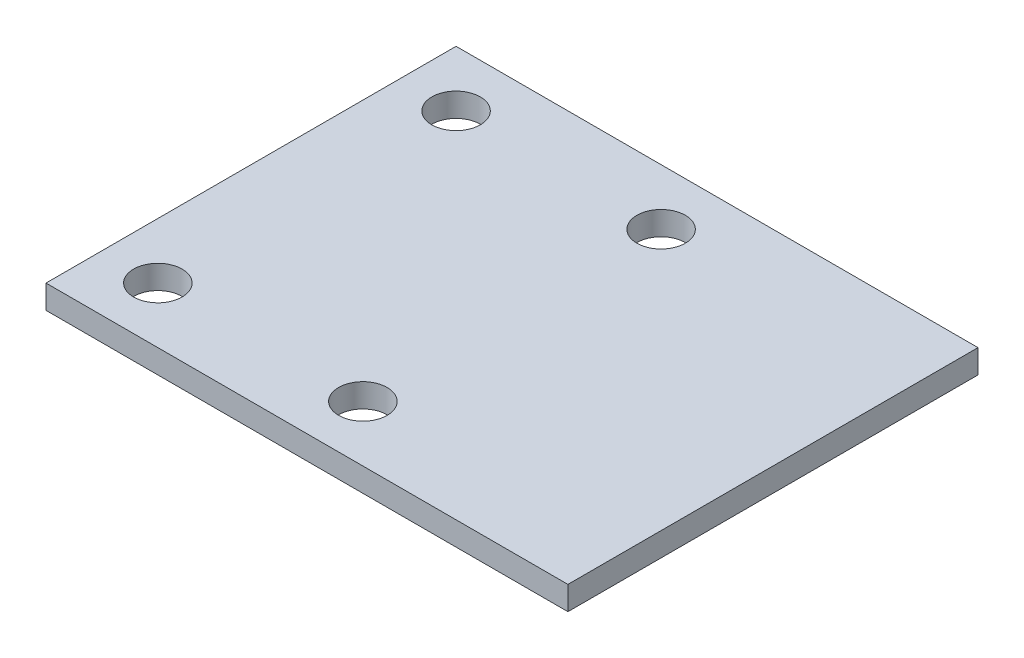
from build123d import *

# Parameters (mm, degrees)
SKETCH1_W            = 28
SKETCH1_H            = 22
BOSS_EXTRUDE1_DEPTH  = 1.27
SKETCH2_R            = 1.2999974
CUT_EXTRUDE2_DEPTH   = 2.27
LPATTERN1_COUNT      = 2
LPATTERN1_PITCH      = 11
LPATTERN1_COUNT_DIR2 = 2
LPATTERN1_PITCH_DIR2 = 16


with BuildPart() as part:
    # Sketch1 → Boss-Extrude1 (new body)
    with BuildSketch(Plane(origin=(0, 0, 0), x_dir=(1, 0, 0), z_dir=(0, 1, 0))):
        Rectangle(SKETCH1_W, SKETCH1_H)
    extrude(amount=BOSS_EXTRUDE1_DEPTH)

    # Sketch2 → Cut-Extrude2 (cut, through all)
    with BuildSketch(Plane(origin=(0, 0, 0), x_dir=(1, 0, 0), z_dir=(0, 1, 0))):
        with Locations((-11, 8)):
            Circle(SKETCH2_R)
    cut_extrude2 = extrude(amount=CUT_EXTRUDE2_DEPTH, mode=Mode.SUBTRACT)

    # LPattern1: Cut-Extrude2 2 × 2
    with Locations(*[(i * LPATTERN1_PITCH, 0, j * LPATTERN1_PITCH_DIR2) for i in range(LPATTERN1_COUNT) for j in range(LPATTERN1_COUNT_DIR2) if (i, j) != (0, 0)]):
        add(cut_extrude2, mode=Mode.SUBTRACT)


solid = part.part
